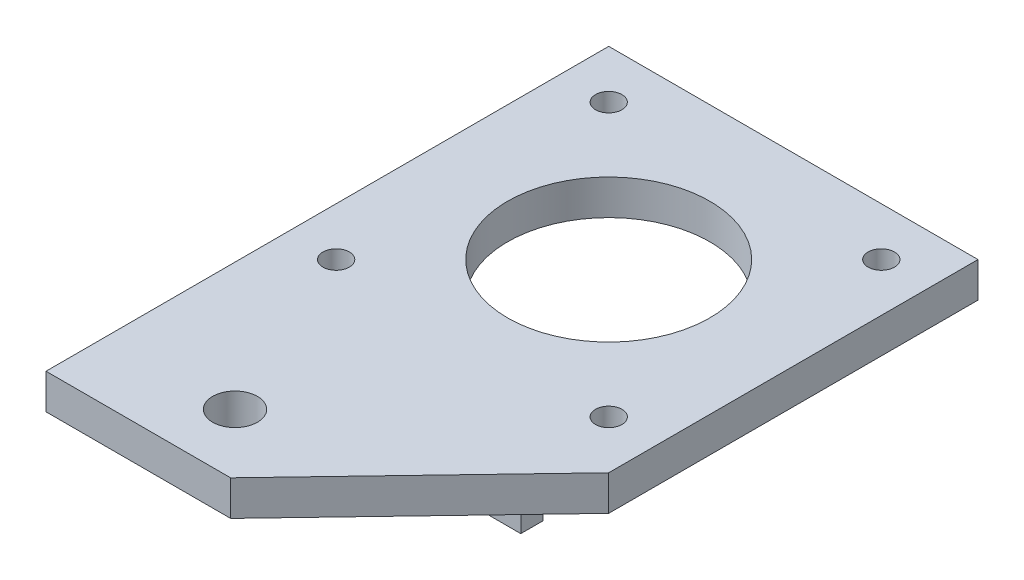
from build123d import *

# Parameters (mm, degrees)
SKETCH1_R           = 2.55
SKETCH1_W           = 42
SKETCH1_H           = 42
SKETCH1_R_2         = 1.5
SKETCH1_R_3         = 11.5
BOSS_EXTRUDE1_DEPTH = 4
SKETCH2_W           = 35
SKETCH2_H           = 2.5
BOSS_EXTRUDE2_DEPTH = 4


with BuildPart() as part:
    # Sketch1 → Boss-Extrude1 (new body)
    with BuildSketch(Plane(origin=(0, 0, 0), x_dir=(1, 0, 0), z_dir=(0, 1, 0))):
        Polygon((0, -22), (21, -22), (42, 0), (0, 0), align=None)
        with Locations((14.5, -15)):
            Circle(SKETCH1_R, mode=Mode.SUBTRACT)
        with Locations((21, 21)):
            Rectangle(SKETCH1_W, SKETCH1_H)
        with Locations((36.5, 36.5)):
            Circle(SKETCH1_R_2, mode=Mode.SUBTRACT)
        with Locations((21, 21)):
            Circle(SKETCH1_R_3, mode=Mode.SUBTRACT)
        with Locations((5.5, 36.5)):
            Circle(SKETCH1_R_2, mode=Mode.SUBTRACT)
        with Locations((36.5, 5.5)):
            Circle(SKETCH1_R_2, mode=Mode.SUBTRACT)
        with Locations((5.5, 5.5)):
            Circle(SKETCH1_R_2, mode=Mode.SUBTRACT)
    extrude(amount=BOSS_EXTRUDE1_DEPTH)

    # Sketch2 → Boss-Extrude2 (add)
    with BuildSketch(Plane.XZ):
        with Locations((17.5, 1.75)):
            Rectangle(SKETCH2_W, SKETCH2_H)
    extrude(amount=BOSS_EXTRUDE2_DEPTH)


solid = part.part
